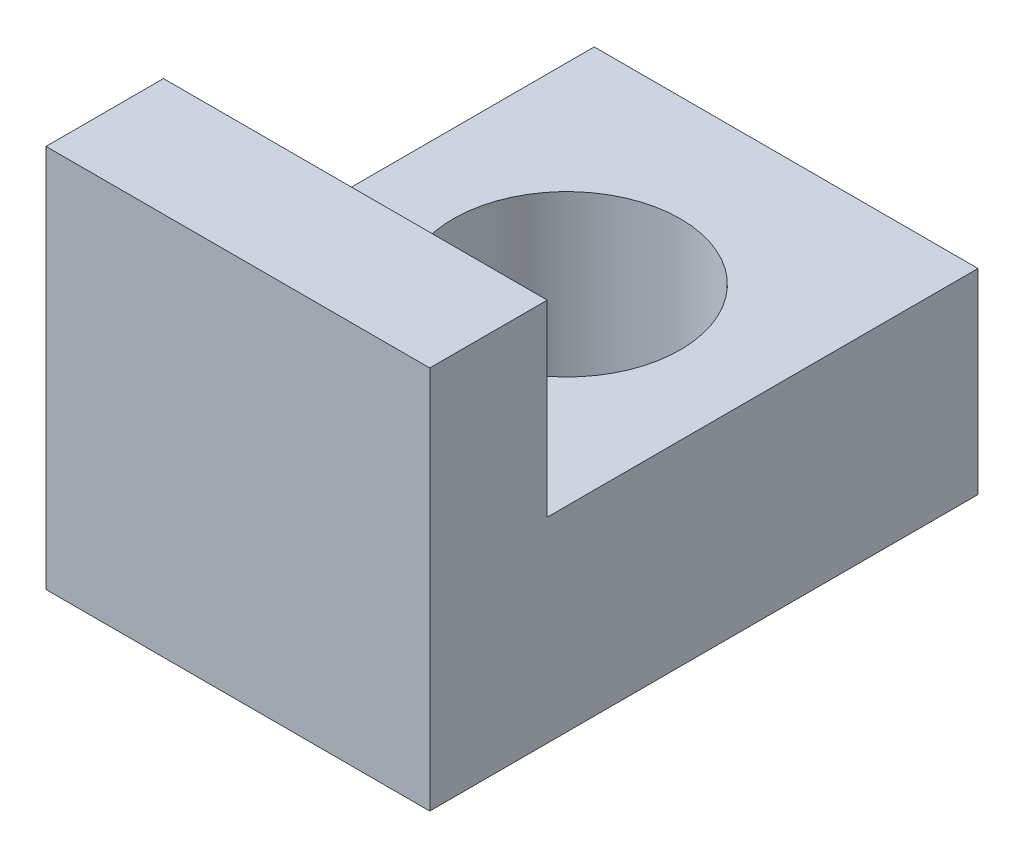
from build123d import *

# Parameters (mm, degrees)
BOSS_EXTRUDE1_DEPTH = 4.9
SKETCH2_R           = 1.45
CUT_EXTRUDE1_DEPTH  = 5.9


with BuildPart() as part:
    # Sketch1 → Boss-Extrude1 (new body)
    with BuildSketch(Plane(origin=(0, 0, 0), x_dir=(0, 0, -1), z_dir=(1, 0, 0))):
        Polygon((0, 0), (0, 4.9), (1.5, 4.9), (1.5, 2.5), (7, 2.5), (7, 0), align=None)
    extrude(amount=BOSS_EXTRUDE1_DEPTH)

    # Sketch2 → Cut-Extrude1 (cut, through all)
    with BuildSketch(Plane.XZ):
        with Locations((2.45, -4.2)):
            Circle(SKETCH2_R)
    extrude(amount=-CUT_EXTRUDE1_DEPTH, mode=Mode.SUBTRACT)


solid = part.part
